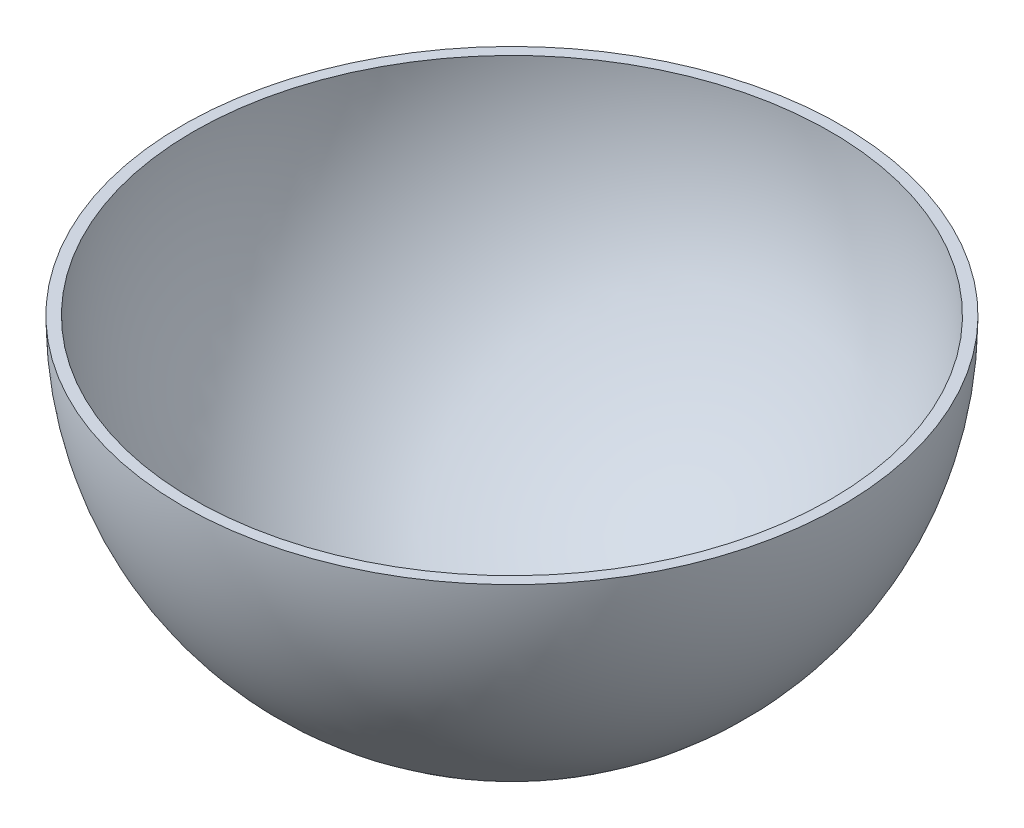
from build123d import *

# Parameters (mm, degrees)
REVOLVE1_ANGLE     = 180
CUT_REVOLVE1_ANGLE = 180


with BuildPart() as part:
    # Sketch1 → Revolve1 (revolve)
    with BuildSketch(Plane(origin=(0, 0, 0), x_dir=(1, 0, 0), z_dir=(0, 1, 0))):
        with BuildLine():
            Line((0, 0), (0, 38.1))
            ThreePointArc((0, 38.1), (-38.1, 0), (0, -38.1))
            Line((0, -38.1), (0, 0))
        make_face()
    revolve(axis=Axis((0, 0, 0), (0, 0, 1)), revolution_arc=REVOLVE1_ANGLE)

    # Sketch2 → Cut-Revolve1 (revolve, cut)
    with BuildSketch(Plane(origin=(0, 0, 0), x_dir=(1, 0, 0), z_dir=(0, 1, 0))):
        with BuildLine():
            Line((0, 36.83), (0, -36.83))
            ThreePointArc((0, -36.83), (-36.83, 0), (0, 36.83))
        make_face()
    revolve(axis=Axis((0, 0, -36.83), (0, 0, 1)), revolution_arc=CUT_REVOLVE1_ANGLE, mode=Mode.SUBTRACT)


solid = part.part
